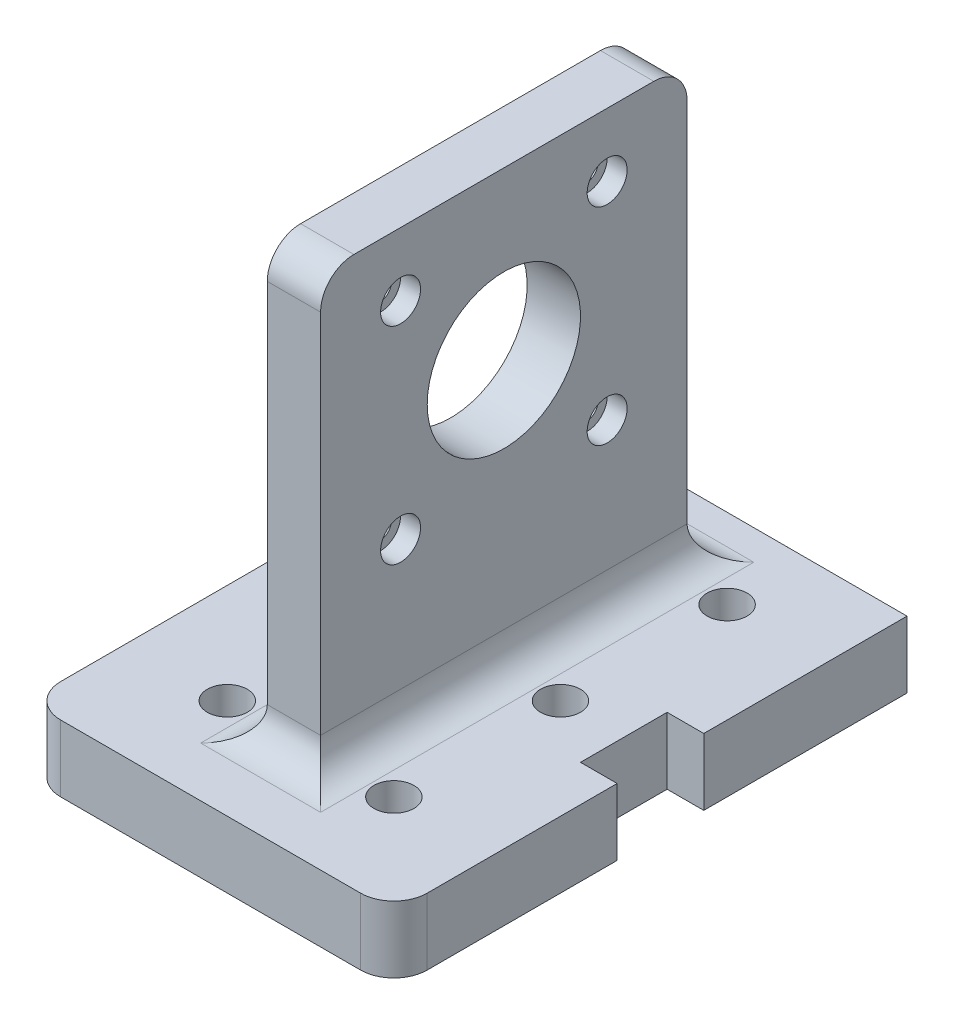
from build123d import *

# Parameters (mm, degrees)
SKETCH1_W               = 55
SKETCH1_H               = 80
BOSS_EXTRUDE1_DEPTH     = 10
SKETCH6_R               = 1.65
CUT_EXTRUDE2_DEPTH      = 55
LPATTERN1_COUNT         = 3
LPATTERN1_PITCH         = 25
MIRROR3_COPY_1_SKETCH_R = 1.65
MIRROR3_COPY_1_DEPTH    = 55
MIRROR3_COPY_2_SKETCH_R = 1.65
MIRROR3_COPY_2_DEPTH    = 55
SKETCH8_W               = 8
SKETCH8_H               = 55
BOSS_EXTRUDE3_DEPTH     = 65
FILLET3_R               = 5
SKETCH9_R               = 1.6
SKETCH9_R_2             = 11.5
CUT_EXTRUDE3_DEPTH      = 32.5
SKETCH10_R              = 3
CUT_EXTRUDE4_DEPTH      = 3
CUT_EXTRUDE5_START      = -5
SKETCH11_R              = 3
CUT_EXTRUDE5_DEPTH      = 71
LPATTERN2_COUNT         = 3
LPATTERN2_PITCH         = 25
MIRROR4_START           = -5
MIRROR4_COPY_1_SKETCH_R = 3
MIRROR4_COPY_1_DEPTH    = 71
MIRROR4_COPY_2_SKETCH_R = 3
MIRROR4_COPY_2_DEPTH    = 71
SKETCH12_W              = 11
SKETCH12_H              = 13
CUT_EXTRUDE6_DEPTH      = 11
CUT_EXTRUDE7_DEPTH      = 10


with BuildPart() as part:
    # Sketch1 → Boss-Extrude1 (new body)
    with BuildSketch(Plane(origin=(0, 0, 0), x_dir=(1, 0, 0), z_dir=(0, 1, 0))):
        Rectangle(SKETCH1_W, SKETCH1_H)
    extrude(amount=BOSS_EXTRUDE1_DEPTH)

    # Sketch6 → Cut-Extrude2 (cut)
    with BuildSketch(Plane(origin=(0, 10, 0), x_dir=(1, 0, 0), z_dir=(0, 1, 0))):
        with Locations((-12.5, -25)):
            Circle(SKETCH6_R)
    cut_extrude2 = extrude(amount=-CUT_EXTRUDE2_DEPTH, mode=Mode.SUBTRACT)

    # LPattern1: Cut-Extrude2 ×3
    with Locations(*[(0, 0, -i * LPATTERN1_PITCH) for i in range(1, LPATTERN1_COUNT)]):
        add(cut_extrude2, mode=Mode.SUBTRACT)

    # Mirror3: Cut-Extrude2 across plane
    add(cut_extrude2.mirror(Plane(origin=(0, 0, 0), x_dir=(0, 0, 1), z_dir=(1, 0, 0))), mode=Mode.SUBTRACT)

    # Mirror3 copy 1 sketch → Mirror3 copy 1 (cut)
    with BuildSketch(Plane(origin=(0, 10, -25), x_dir=(-1, 0, 0), z_dir=(0, 1, 0))):
        with Locations((-12.5, 25)):
            Circle(MIRROR3_COPY_1_SKETCH_R)
    extrude(amount=-MIRROR3_COPY_1_DEPTH, mode=Mode.SUBTRACT)

    # Mirror3 copy 2 sketch → Mirror3 copy 2 (cut)
    with BuildSketch(Plane(origin=(0, 10, -50), x_dir=(-1, 0, 0), z_dir=(0, 1, 0))):
        with Locations((-12.5, 25)):
            Circle(MIRROR3_COPY_2_SKETCH_R)
    extrude(amount=-MIRROR3_COPY_2_DEPTH, mode=Mode.SUBTRACT)

    # Sketch8 → Boss-Extrude3 (add)
    with BuildSketch(Plane(origin=(0, 10, 0), x_dir=(1, 0, 0), z_dir=(0, 1, 0))):
        Rectangle(SKETCH8_W, SKETCH8_H)
    extrude(amount=BOSS_EXTRUDE3_DEPTH)

    # Fillet3
    fillet3_edges = [part.edges().sort_by_distance(p)[0] for p in [
        (4, 10, 0),
        (0, 10, -27.5),
        (-4, 10, 0),
        (0, 10, 27.5),
        (0, 75, -27.5),
        (0, 75, 27.5),
        (27.5, 5, 40),
        (-27.5, 5, 40),
    ]]
    fillet(fillet3_edges, radius=FILLET3_R)

    # Sketch9 → Cut-Extrude3 (cut, through all)
    with BuildSketch(Plane.ZY.offset(4)):
        with Locations((-15.5, 65.5)):
            Circle(SKETCH9_R)
        with Locations((15.5, 65.5)):
            Circle(SKETCH9_R)
        with Locations((-15.5, 34.5)):
            Circle(SKETCH9_R)
        with Locations((15.5, 34.5)):
            Circle(SKETCH9_R)
        with Locations((0, 50)):
            Circle(SKETCH9_R_2)
    extrude(amount=-CUT_EXTRUDE3_DEPTH, mode=Mode.SUBTRACT)

    # Sketch10 → Cut-Extrude4 (cut)
    with BuildSketch(Plane(origin=(4, 0, 0), x_dir=(0, 0, -1), z_dir=(1, 0, 0))):
        with Locations((-15.5, 65.5)):
            Circle(SKETCH10_R)
        with Locations((15.5, 65.5)):
            Circle(SKETCH10_R)
        with Locations((15.5, 34.5)):
            Circle(SKETCH10_R)
        with Locations((-15.5, 34.5)):
            Circle(SKETCH10_R)
    extrude(amount=-CUT_EXTRUDE4_DEPTH, mode=Mode.SUBTRACT)

    # Sketch11 → Cut-Extrude5 (cut)
    with BuildSketch(Plane(origin=(0, 10, 0), x_dir=(1, 0, 0), z_dir=(0, 1, 0)).offset(CUT_EXTRUDE5_START)):
        with Locations((-12.5, -25)):
            Circle(SKETCH11_R)
    cut_extrude5 = extrude(amount=CUT_EXTRUDE5_DEPTH, mode=Mode.SUBTRACT)

    # LPattern2: Cut-Extrude5 ×3
    with Locations(*[(0, 0, -i * LPATTERN2_PITCH) for i in range(1, LPATTERN2_COUNT)]):
        add(cut_extrude5, mode=Mode.SUBTRACT)

    # Mirror4: Cut-Extrude5 across plane
    add(cut_extrude5.mirror(Plane(origin=(0, 0, 0), x_dir=(0, 0, 1), z_dir=(1, 0, 0))), mode=Mode.SUBTRACT)

    # Mirror4 copy 1 sketch → Mirror4 copy 1 (cut)
    with BuildSketch(Plane(origin=(0, 10, -25), x_dir=(-1, 0, 0), z_dir=(0, 1, 0)).offset(MIRROR4_START)):
        with Locations((-12.5, 25)):
            Circle(MIRROR4_COPY_1_SKETCH_R)
    extrude(amount=MIRROR4_COPY_1_DEPTH, mode=Mode.SUBTRACT)

    # Mirror4 copy 2 sketch → Mirror4 copy 2 (cut)
    with BuildSketch(Plane(origin=(0, 10, -50), x_dir=(-1, 0, 0), z_dir=(0, 1, 0)).offset(MIRROR4_START)):
        with Locations((-12.5, 25)):
            Circle(MIRROR4_COPY_2_SKETCH_R)
    extrude(amount=MIRROR4_COPY_2_DEPTH, mode=Mode.SUBTRACT)

    # Sketch12 → Cut-Extrude6 (cut, through all)
    with BuildSketch(Plane(origin=(0, 10, 0), x_dir=(1, 0, 0), z_dir=(0, 1, 0))):
        with Locations((27.5, 0)):
            Rectangle(SKETCH12_W, SKETCH12_H)
    extrude(amount=-CUT_EXTRUDE6_DEPTH, mode=Mode.SUBTRACT)

    # Sketch13 → Cut-Extrude7 (cut)
    with BuildSketch(Plane(origin=(0, 10, 0), x_dir=(1, 0, 0), z_dir=(0, 1, 0))):
        Polygon((-12.5, 37), (34.859752384, 37), (34.859752384, 45.853513443), (-44.482070636, 45.853513443), (-44.482070636, 37), align=None)
    extrude(amount=-CUT_EXTRUDE7_DEPTH, mode=Mode.SUBTRACT)


solid = part.part
